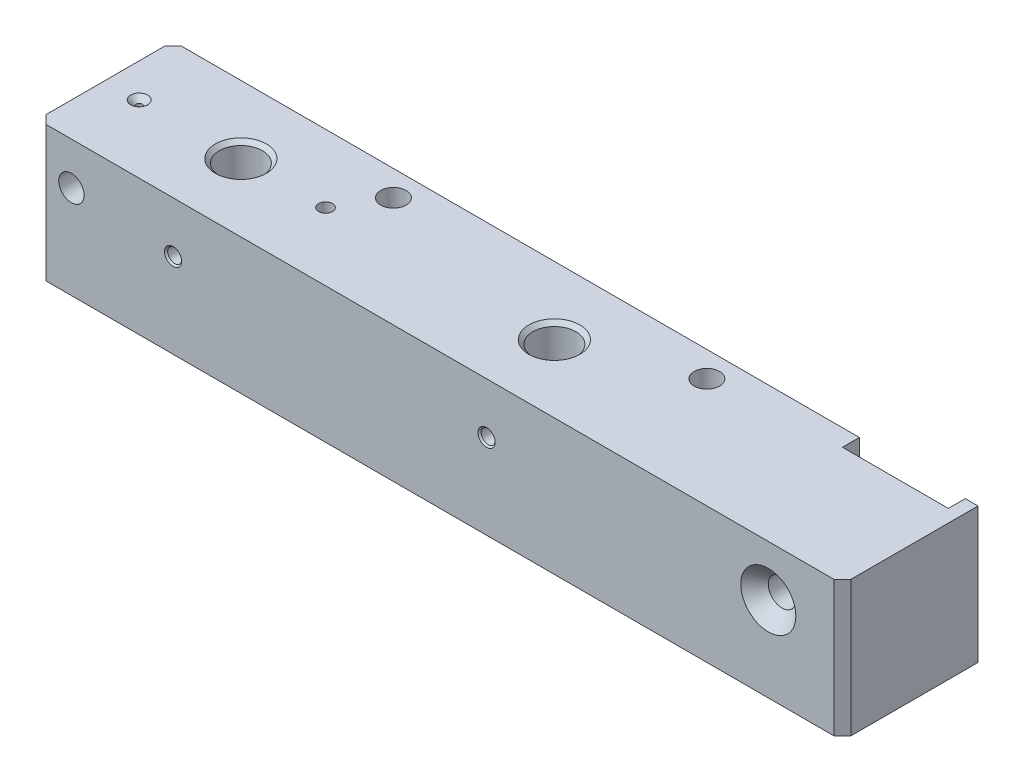
from build123d import *

# Parameters (mm, degrees)
SKETCH1_W                                            = 190
SKETCH1_H                                            = 32
BOSS_EXTRUDE1_DEPTH                                  = 16
CHAMFER1_SIZE                                        = 2
SKETCH2_W                                            = 25
SKETCH2_H                                            = 4
CUT_EXTRUDE1_DEPTH                                   = 33
M12_TAPPED_HOLE1_D                                   = 10.2
M12_TAPPED_HOLE1_DEPTH                               = 24
M12_TAPPED_HOLE1_CSINK_D                             = 12.05
M12_TAPPED_HOLE1_CSINK_ANGLE                         = 90
M12_TAPPED_HOLE1_TIP                                 = 3.064389157
M4_TAPPED_HOLE1_D                                    = 3.3
M4_TAPPED_HOLE1_DEPTH                                = 11.5
M4_TAPPED_HOLE1_CSINK_D                              = 4.05
M4_TAPPED_HOLE1_CSINK_ANGLE                          = 90
M4_TAPPED_HOLE1_TIP                                  = 0.991420021
CSK_FOR_M10_COUNTERSUNK_FLAT_HEAD_SCREW1_D           = 6.5
CSK_FOR_M10_COUNTERSUNK_FLAT_HEAD_SCREW1_CSINK_D     = 13
CSK_FOR_M10_COUNTERSUNK_FLAT_HEAD_SCREW1_CSINK_ANGLE = 90
SKETCH12_R                                           = 3
CUT_EXTRUDE2_DEPTH                                   = 33
CSK_FOR_M4_COUNTERSUNK_FLAT_HEAD_SCREW1_D            = 1.5
CSK_FOR_M4_COUNTERSUNK_FLAT_HEAD_SCREW1_DEPTH        = 11.5
CSK_FOR_M4_COUNTERSUNK_FLAT_HEAD_SCREW1_CSINK_D      = 4
CSK_FOR_M4_COUNTERSUNK_FLAT_HEAD_SCREW1_CSINK_ANGLE  = 90
CSK_FOR_M4_COUNTERSUNK_FLAT_HEAD_SCREW1_TIP          = 0.450645464
M4_TAPPED_HOLE2_D                                    = 3.3
M4_TAPPED_HOLE2_DEPTH                                = 16
M4_TAPPED_HOLE2_TIP                                  = 0.991420021
SKETCH19_R                                           = 3
CUT_EXTRUDE3_DEPTH                                   = 33


with BuildPart() as part:
    # Sketch1 → Boss-Extrude1 (new body, symmetric)
    with BuildSketch(Plane.XY):
        Rectangle(SKETCH1_W, SKETCH1_H)
    extrude(amount=BOSS_EXTRUDE1_DEPTH, both=True)

    # Chamfer1
    chamfer1_edges = [part.edges().sort_by_distance(p)[0] for p in [
        (-95, 0, 16),
        (95, 0, 16),
        (-95, 0, -16),
    ]]
    chamfer(chamfer1_edges, length=CHAMFER1_SIZE)

    # Sketch2 → Cut-Extrude1 (cut, through all)
    with BuildSketch(Plane(origin=(0, 16, 0), x_dir=(1, 0, 0), z_dir=(0, 1, 0))):
        with Locations((79.5, 14)):
            Rectangle(SKETCH2_W, SKETCH2_H)
    extrude(amount=-CUT_EXTRUDE1_DEPTH, mode=Mode.SUBTRACT)

    # M12 Tapped Hole1
    with Locations(Plane(origin=(0, 16, 0), x_dir=(1, 0, 0), z_dir=(0, 1, 0))):
        with Locations((-63, 0), (11, 0)):
            CounterSinkHole(M12_TAPPED_HOLE1_D / 2, M12_TAPPED_HOLE1_CSINK_D / 2, depth=M12_TAPPED_HOLE1_DEPTH, counter_sink_angle=M12_TAPPED_HOLE1_CSINK_ANGLE)
            with Locations((0, 0, -(M12_TAPPED_HOLE1_DEPTH + M12_TAPPED_HOLE1_TIP / 2))):  # 118° drill point
                Cone(0, M12_TAPPED_HOLE1_D / 2, M12_TAPPED_HOLE1_TIP, mode=Mode.SUBTRACT)

    # M4 Tapped Hole1
    with Locations(Plane.XY.offset(16)):
        with Locations((-63, 4), (11, 4)):
            CounterSinkHole(M4_TAPPED_HOLE1_D / 2, M4_TAPPED_HOLE1_CSINK_D / 2, depth=M4_TAPPED_HOLE1_DEPTH, counter_sink_angle=M4_TAPPED_HOLE1_CSINK_ANGLE)
            with Locations((0, 0, -(M4_TAPPED_HOLE1_DEPTH + M4_TAPPED_HOLE1_TIP / 2))):  # 118° drill point
                Cone(0, M4_TAPPED_HOLE1_D / 2, M4_TAPPED_HOLE1_TIP, mode=Mode.SUBTRACT)

    # CSK for M10 Countersunk Flat Head Screw1 (through all)
    with Locations(Plane.XY.offset(16)):
        with Locations((77.5, 4)):
            CounterSinkHole(CSK_FOR_M10_COUNTERSUNK_FLAT_HEAD_SCREW1_D / 2, CSK_FOR_M10_COUNTERSUNK_FLAT_HEAD_SCREW1_CSINK_D / 2, counter_sink_angle=CSK_FOR_M10_COUNTERSUNK_FLAT_HEAD_SCREW1_CSINK_ANGLE)

    # Sketch12 → Cut-Extrude2 (cut, through all)
    with BuildSketch(Plane.XY.offset(16)):
        with Locations((-87, 6)):
            Circle(SKETCH12_R)
    extrude(amount=-CUT_EXTRUDE2_DEPTH, mode=Mode.SUBTRACT)

    # CSK for M4 Countersunk Flat Head Screw1
    with Locations(Plane(origin=(0, 16, 0), x_dir=(1, 0, 0), z_dir=(0, 1, 0))):
        with Locations((-87, 0)):
            CounterSinkHole(CSK_FOR_M4_COUNTERSUNK_FLAT_HEAD_SCREW1_D / 2, CSK_FOR_M4_COUNTERSUNK_FLAT_HEAD_SCREW1_CSINK_D / 2, depth=CSK_FOR_M4_COUNTERSUNK_FLAT_HEAD_SCREW1_DEPTH, counter_sink_angle=CSK_FOR_M4_COUNTERSUNK_FLAT_HEAD_SCREW1_CSINK_ANGLE)
            with Locations((0, 0, -(CSK_FOR_M4_COUNTERSUNK_FLAT_HEAD_SCREW1_DEPTH + CSK_FOR_M4_COUNTERSUNK_FLAT_HEAD_SCREW1_TIP / 2))):  # 118° drill point
                Cone(0, CSK_FOR_M4_COUNTERSUNK_FLAT_HEAD_SCREW1_D / 2, CSK_FOR_M4_COUNTERSUNK_FLAT_HEAD_SCREW1_TIP, mode=Mode.SUBTRACT)

    # M4 Tapped Hole2
    with Locations(Plane(origin=(0, 16, 0), x_dir=(1, 0, 0), z_dir=(0, 1, 0))):
        with Locations((-43, 0)):
            Hole(M4_TAPPED_HOLE2_D / 2, depth=M4_TAPPED_HOLE2_DEPTH)
            with Locations((0, 0, -(M4_TAPPED_HOLE2_DEPTH + M4_TAPPED_HOLE2_TIP / 2))):  # 118° drill point
                Cone(0, M4_TAPPED_HOLE2_D / 2, M4_TAPPED_HOLE2_TIP, mode=Mode.SUBTRACT)

    # Sketch19 → Cut-Extrude3 (cut, through all)
    with BuildSketch(Plane(origin=(0, 16, 0), x_dir=(1, 0, 0), z_dir=(0, 1, 0))):
        with Locations((-37, 10)):
            Circle(SKETCH19_R)
        with Locations((37, 10)):
            Circle(SKETCH19_R)
    extrude(amount=-CUT_EXTRUDE3_DEPTH, mode=Mode.SUBTRACT)


solid = part.part
